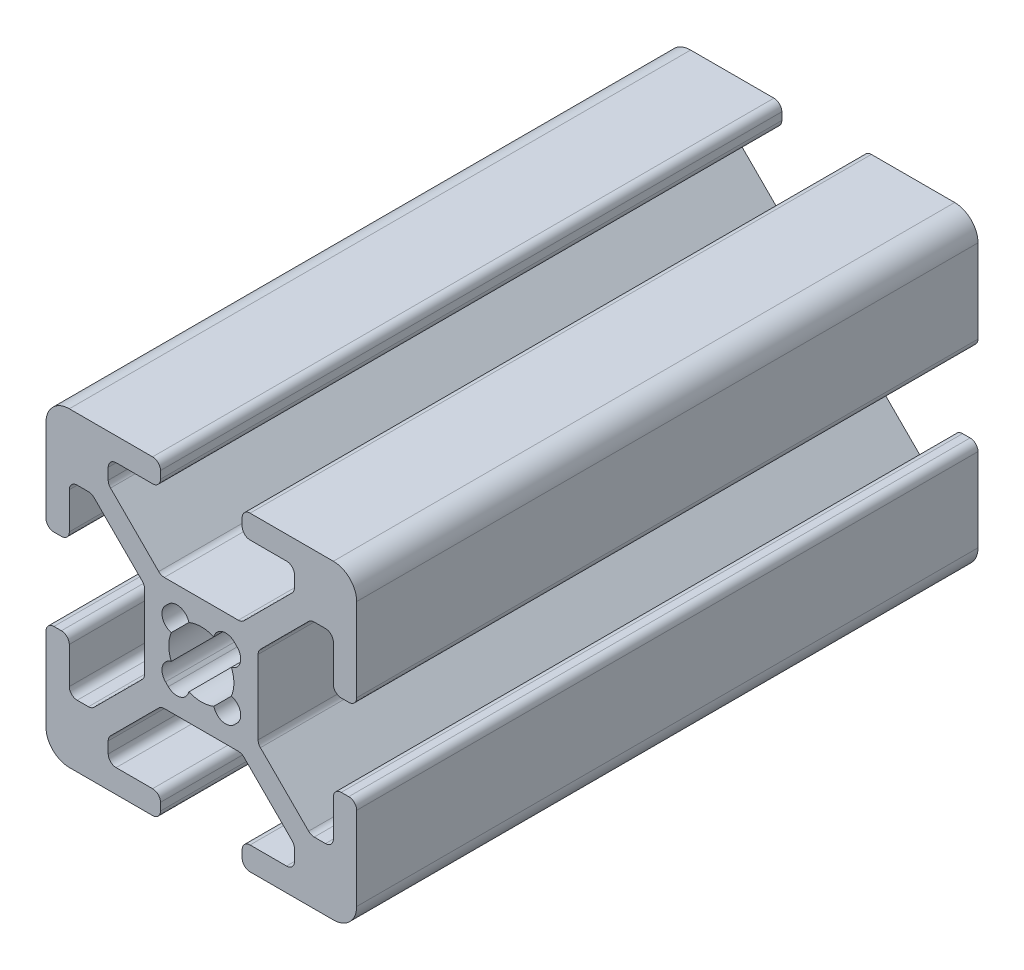
from build123d import *

# Parameters (mm, degrees)
EXTRUDE1_DEPTH = 40


with BuildPart() as part:
    # Sketch1 → Extrude1 (new body)
    with BuildSketch(Plane.XY):
        with BuildLine():
            Line((-5.032287798, -0.341059771), (-5.516287798, -0.341059771))
            ThreePointArc((-5.516287798, -0.341059771), (-5.875498042, -0.192270016), (-6.024287798, 0.166940229))
            Line((-6.024287798, 0.166940229), (-6.024287798, 2.515940229))
            ThreePointArc((-6.024287798, 2.515940229), (-6.173077553, 2.875150474), (-6.532287798, 3.023940229))
            Line((-6.532287798, 3.023940229), (-7.258207136, 3.023940229))
            ThreePointArc((-7.258207136, 3.023940229), (-7.45261032, 2.985271032), (-7.617417381, 2.875150474))
            Line((-7.617417381, 2.875150474), (-10.720498042, -0.227930187))
            ThreePointArc((-10.720498042, -0.227930187), (-10.8306186, -0.392737249), (-10.869287798, -0.587140432))
            Line((-10.869287798, -0.587140432), (-10.869287798, -5.354979109))
            ThreePointArc((-10.869287798, -5.354979109), (-10.8306186, -5.549382293), (-10.720498042, -5.714189354))
            Line((-10.720498042, -5.714189354), (-7.617417381, -8.817270016))
            ThreePointArc((-7.617417381, -8.817270016), (-7.45261032, -8.927390573), (-7.258207136, -8.966059771))
            Line((-7.258207136, -8.966059771), (-6.532287798, -8.966059771))
            ThreePointArc((-6.532287798, -8.966059771), (-6.173077553, -8.817270016), (-6.024287798, -8.458059771))
            Line((-6.024287798, -8.458059771), (-6.024287798, -6.109059771))
            ThreePointArc((-6.024287798, -6.109059771), (-5.875498042, -5.749849526), (-5.516287798, -5.601059771))
            Line((-5.516287798, -5.601059771), (-5.032287798, -5.601059771))
            ThreePointArc((-5.032287798, -5.601059771), (-4.673077553, -5.749849526), (-4.524287798, -6.109059771))
            Line((-4.524287798, -6.109059771), (-4.524287798, -11.471059771))
            ThreePointArc((-4.524287798, -11.471059771), (-4.963627626, -12.531719943), (-6.024287798, -12.971059771))
            Line((-6.024287798, -12.971059771), (-11.386287798, -12.971059771))
            ThreePointArc((-11.386287798, -12.971059771), (-11.745498042, -12.822270016), (-11.894287798, -12.463059771))
            Line((-11.894287798, -12.463059771), (-11.894287798, -11.979059771))
            ThreePointArc((-11.894287798, -11.979059771), (-11.745498042, -11.619849526), (-11.386287798, -11.471059771))
            Line((-11.386287798, -11.471059771), (-9.037287798, -11.471059771))
            ThreePointArc((-9.037287798, -11.471059771), (-8.678077553, -11.322270016), (-8.529287798, -10.963059771))
            Line((-8.529287798, -10.963059771), (-8.529287798, -10.237140432))
            ThreePointArc((-8.529287798, -10.237140432), (-8.567956995, -10.042737249), (-8.678077553, -9.877930187))
            Line((-8.678077553, -9.877930187), (-11.781158214, -6.774849526))
            ThreePointArc((-11.781158214, -6.774849526), (-11.945965275, -6.664728968), (-12.140368459, -6.626059771))
            Line((-12.140368459, -6.626059771), (-16.908207136, -6.626059771))
            ThreePointArc((-16.908207136, -6.626059771), (-17.10261032, -6.664728968), (-17.267417381, -6.774849526))
            Line((-17.267417381, -6.774849526), (-20.370498042, -9.877930187))
            ThreePointArc((-20.370498042, -9.877930187), (-20.4806186, -10.042737249), (-20.519287798, -10.237140432))
            Line((-20.519287798, -10.237140432), (-20.519287798, -10.963059771))
            ThreePointArc((-20.519287798, -10.963059771), (-20.370498042, -11.322270016), (-20.011287798, -11.471059771))
            Line((-20.011287798, -11.471059771), (-17.662287798, -11.471059771))
            ThreePointArc((-17.662287798, -11.471059771), (-17.303077553, -11.619849526), (-17.154287798, -11.979059771))
            Line((-17.154287798, -11.979059771), (-17.154287798, -12.463059771))
            ThreePointArc((-17.154287798, -12.463059771), (-17.303077553, -12.822270016), (-17.662287798, -12.971059771))
            Line((-17.662287798, -12.971059771), (-23.024287798, -12.971059771))
            ThreePointArc((-23.024287798, -12.971059771), (-24.084947969, -12.531719943), (-24.524287798, -11.471059771))
            Line((-24.524287798, -11.471059771), (-24.524287798, -6.109059771))
            ThreePointArc((-24.524287798, -6.109059771), (-24.375498042, -5.749849526), (-24.016287798, -5.601059771))
            Line((-24.016287798, -5.601059771), (-23.532287798, -5.601059771))
            ThreePointArc((-23.532287798, -5.601059771), (-23.173077553, -5.749849526), (-23.024287798, -6.109059771))
            Line((-23.024287798, -6.109059771), (-23.024287798, -8.458059771))
            ThreePointArc((-23.024287798, -8.458059771), (-22.875498042, -8.817270016), (-22.516287798, -8.966059771))
            Line((-22.516287798, -8.966059771), (-21.790368459, -8.966059771))
            ThreePointArc((-21.790368459, -8.966059771), (-21.595965275, -8.927390573), (-21.431158214, -8.817270016))
            Line((-21.431158214, -8.817270016), (-18.328077553, -5.714189354))
            ThreePointArc((-18.328077553, -5.714189354), (-18.217956995, -5.549382293), (-18.179287798, -5.354979109))
            Line((-18.179287798, -5.354979109), (-18.179287798, -0.587140432))
            ThreePointArc((-18.179287798, -0.587140432), (-18.217956995, -0.392737249), (-18.328077553, -0.227930187))
            Line((-18.328077553, -0.227930187), (-21.431158214, 2.875150474))
            ThreePointArc((-21.431158214, 2.875150474), (-21.595965275, 2.985271032), (-21.790368459, 3.023940229))
            Line((-21.790368459, 3.023940229), (-22.516287798, 3.023940229))
            ThreePointArc((-22.516287798, 3.023940229), (-22.875498042, 2.875150474), (-23.024287798, 2.515940229))
            Line((-23.024287798, 2.515940229), (-23.024287798, 0.166940229))
            ThreePointArc((-23.024287798, 0.166940229), (-23.173077553, -0.192270016), (-23.532287798, -0.341059771))
            Line((-23.532287798, -0.341059771), (-24.016287798, -0.341059771))
            ThreePointArc((-24.016287798, -0.341059771), (-24.375498042, -0.192270016), (-24.524287798, 0.166940229))
            Line((-24.524287798, 0.166940229), (-24.524287798, 5.528940229))
            ThreePointArc((-24.524287798, 5.528940229), (-24.084947969, 6.589600401), (-23.024287798, 7.028940229))
            Line((-23.024287798, 7.028940229), (-17.662287798, 7.028940229))
            ThreePointArc((-17.662287798, 7.028940229), (-17.303077553, 6.880150474), (-17.154287798, 6.520940229))
            Line((-17.154287798, 6.520940229), (-17.154287798, 6.036940229))
            ThreePointArc((-17.154287798, 6.036940229), (-17.303077553, 5.677729984), (-17.662287798, 5.528940229))
            Line((-17.662287798, 5.528940229), (-20.011287798, 5.528940229))
            ThreePointArc((-20.011287798, 5.528940229), (-20.370498042, 5.380150474), (-20.519287798, 5.020940229))
            Line((-20.519287798, 5.020940229), (-20.519287798, 4.295020891))
            ThreePointArc((-20.519287798, 4.295020891), (-20.4806186, 4.100617707), (-20.370498042, 3.935810646))
            Line((-20.370498042, 3.935810646), (-17.267417381, 0.832729984))
            ThreePointArc((-17.267417381, 0.832729984), (-17.10261032, 0.722609427), (-16.908207136, 0.683940229))
            Line((-16.908207136, 0.683940229), (-12.140368459, 0.683940229))
            ThreePointArc((-12.140368459, 0.683940229), (-11.945965275, 0.722609427), (-11.781158214, 0.832729984))
            Line((-11.781158214, 0.832729984), (-8.678077553, 3.935810646))
            ThreePointArc((-8.678077553, 3.935810646), (-8.567956995, 4.100617707), (-8.529287798, 4.295020891))
            Line((-8.529287798, 4.295020891), (-8.529287798, 5.020940229))
            ThreePointArc((-8.529287798, 5.020940229), (-8.678077553, 5.380150474), (-9.037287798, 5.528940229))
            Line((-9.037287798, 5.528940229), (-11.386287798, 5.528940229))
            ThreePointArc((-11.386287798, 5.528940229), (-11.745498042, 5.677729984), (-11.894287798, 6.036940229))
            Line((-11.894287798, 6.036940229), (-11.894287798, 6.520940229))
            ThreePointArc((-11.894287798, 6.520940229), (-11.745498042, 6.880150474), (-11.386287798, 7.028940229))
            Line((-11.386287798, 7.028940229), (-6.024287798, 7.028940229))
            ThreePointArc((-6.024287798, 7.028940229), (-4.963627626, 6.589600401), (-4.524287798, 5.528940229))
            Line((-4.524287798, 5.528940229), (-4.524287798, 0.166940229))
            ThreePointArc((-4.524287798, 0.166940229), (-4.673077553, -0.192270016), (-5.032287798, -0.341059771))
        make_face()
        with BuildLine():
            Line((-12.399386954, -5.275565737), (-12.219781831, -5.095960615))
            ThreePointArc((-12.219781831, -5.095960615), (-12.018349781, -4.327527582), (-12.589154291, -3.775036489))
            ThreePointArc((-12.589154291, -3.775036489), (-12.428787798, -2.971059771), (-12.589154291, -2.167083053))
            ThreePointArc((-12.589154291, -2.167083053), (-12.018349781, -1.61459196), (-12.219781831, -0.846158927))
            Line((-12.219781831, -0.846158927), (-12.399386954, -0.666553805))
            ThreePointArc((-12.399386954, -0.666553805), (-13.167819987, -0.465121754), (-13.72031108, -1.035926265))
            ThreePointArc((-13.72031108, -1.035926265), (-14.524287798, -0.875559771), (-15.328264516, -1.035926265))
            ThreePointArc((-15.328264516, -1.035926265), (-15.880755608, -0.465121754), (-16.649188641, -0.666553805))
            Line((-16.649188641, -0.666553805), (-16.828793764, -0.846158927))
            ThreePointArc((-16.828793764, -0.846158927), (-17.030225814, -1.61459196), (-16.459421304, -2.167083053))
            ThreePointArc((-16.459421304, -2.167083053), (-16.619787798, -2.971059771), (-16.459421304, -3.775036489))
            ThreePointArc((-16.459421304, -3.775036489), (-17.030225814, -4.327527582), (-16.828793764, -5.095960615))
            Line((-16.828793764, -5.095960615), (-16.649188641, -5.275565737))
            ThreePointArc((-16.649188641, -5.275565737), (-15.880755608, -5.476997788), (-15.328264516, -4.906193277))
            ThreePointArc((-15.328264516, -4.906193277), (-14.524287798, -5.066559771), (-13.72031108, -4.906193277))
            ThreePointArc((-13.72031108, -4.906193277), (-13.167819987, -5.476997788), (-12.399386954, -5.275565737))
        make_face(mode=Mode.SUBTRACT)
    extrude(amount=EXTRUDE1_DEPTH)


solid = part.part
